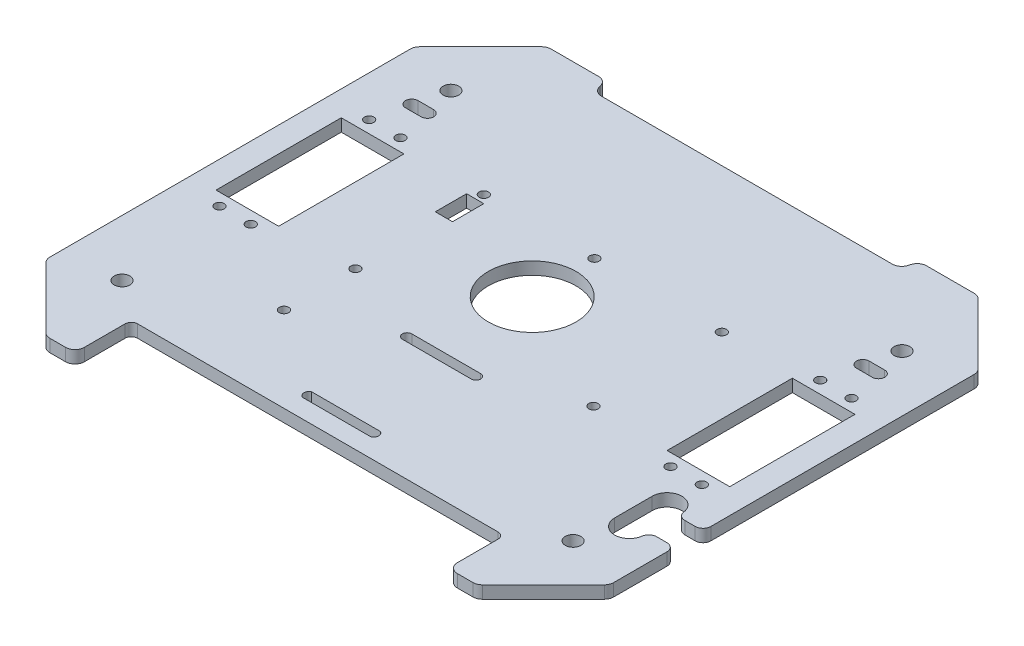
from build123d import *

# Parameters (mm, degrees)
BOSS_EXTRUDE1_DEPTH = 4
CUT_EXTRUDE1_REACH  = 123.301
SKETCH6_R           = 1.5
SKETCH6_R_2         = 2.5
SKETCH6_W           = 20
SKETCH6_H           = 40
SKETCH7_R           = 1.5
CUT_EXTRUDE2_DEPTH  = 122.300839153
SKETCH8_W           = 5.5
SKETCH8_H           = 10
CUT_EXTRUDE3_DEPTH  = 122.300839153
SKETCH9_R           = 1.5
SKETCH9_R_2         = 14
CUT_EXTRUDE4_DEPTH  = 122.300839153


with BuildPart() as part:
    # Sketch1 → Boss-Extrude1 (new body)
    with BuildSketch(Plane(origin=(0, 0, 0), x_dir=(1, 0, 0), z_dir=(0, 1, 0))):
        with BuildLine():
            Line((0, -78.772581113), (0, 81.227418887))
            Line((0, 81.227418887), (67.544155877, 81.227418887))
            ThreePointArc((67.544155877, 81.227418887), (68.692206174, 80.999057485), (69.665476221, 80.348739231))
            Line((69.665476221, 80.348739231), (89.121320344, 60.892895108))
            ThreePointArc((89.121320344, 60.892895108), (89.771638598, 59.919625062), (90, 58.771574765))
            Line((90, 58.771574765), (90, -56.31673699))
            ThreePointArc((90, -56.31673699), (89.771638598, -57.464787287), (89.121320344, -58.438057333))
            Line((89.121320344, -58.438057333), (69.665476221, -77.893901456))
            ThreePointArc((69.665476221, -77.893901456), (68.692206174, -78.54421971), (67.544155877, -78.772581113))
            Line((67.544155877, -78.772581113), (0, -78.772581113))
        make_face()
    boss_extrude1 = extrude(amount=BOSS_EXTRUDE1_DEPTH)

    # Sketch6 → Cut-Extrude1 (cut, up to next)
    with BuildSketch(Plane(origin=(0, 4, 0), x_dir=(1, 0, 0), z_dir=(0, 1, 0)), mode=Mode.PRIVATE) as cut_extrude1_sk1:
        with Locations(Location((67.009618943, 32.627418887, 0), (0, 0, 270))):
            Circle(SKETCH6_R)
    cut_extrude1_tool1 = extrude(cut_extrude1_sk1.sketch, amount=-CUT_EXTRUDE1_REACH, mode=Mode.PRIVATE) & part.part
    # Sketch6 → Cut-Extrude1 (cut, up to next)
    with BuildSketch(Plane(origin=(0, 4, 0), x_dir=(1, 0, 0), z_dir=(0, 1, 0)), mode=Mode.PRIVATE) as cut_extrude1_sk2:
        with Locations(Location((77.009618943, 32.627418887, 0), (0, 0, 270))):
            Circle(SKETCH6_R)
    cut_extrude1_tool2 = extrude(cut_extrude1_sk2.sketch, amount=-CUT_EXTRUDE1_REACH, mode=Mode.PRIVATE) & part.part
    # Sketch6 → Cut-Extrude1 (cut, up to next)
    with BuildSketch(Plane(origin=(0, 4, 0), x_dir=(1, 0, 0), z_dir=(0, 1, 0)), mode=Mode.PRIVATE) as cut_extrude1_sk3:
        with Locations(Location((77.009618943, -15.172581113, 0), (0, 0, 270))):
            Circle(SKETCH6_R)
    cut_extrude1_tool3 = extrude(cut_extrude1_sk3.sketch, amount=-CUT_EXTRUDE1_REACH, mode=Mode.PRIVATE) & part.part
    # Sketch6 → Cut-Extrude1 (cut, up to next)
    with BuildSketch(Plane(origin=(0, 4, 0), x_dir=(1, 0, 0), z_dir=(0, 1, 0)), mode=Mode.PRIVATE) as cut_extrude1_sk4:
        with Locations(Location((67.009618943, -15.172581113, 0), (0, 0, 270))):
            Circle(SKETCH6_R)
    cut_extrude1_tool4 = extrude(cut_extrude1_sk4.sketch, amount=-CUT_EXTRUDE1_REACH, mode=Mode.PRIVATE) & part.part
    # Sketch6 → Cut-Extrude1 (cut, up to next)
    with BuildSketch(Plane(origin=(0, 4, 0), x_dir=(1, 0, 0), z_dir=(0, 1, 0)), mode=Mode.PRIVATE) as cut_extrude1_sk5:
        with Locations(Location((72.009618943, 53.727418887, 0), (0, 0, 270))):
            Circle(SKETCH6_R_2)
    cut_extrude1_tool5 = extrude(cut_extrude1_sk5.sketch, amount=-CUT_EXTRUDE1_REACH, mode=Mode.PRIVATE) & part.part
    # Sketch6 → Cut-Extrude1 (cut, up to next)
    with BuildSketch(Plane(origin=(0, 4, 0), x_dir=(1, 0, 0), z_dir=(0, 1, 0)), mode=Mode.PRIVATE) as cut_extrude1_sk6:
        with Locations(Location((72.009618943, -51.272581113, 0), (0, 0, 270))):
            Circle(SKETCH6_R_2)
    cut_extrude1_tool6 = extrude(cut_extrude1_sk6.sketch, amount=-CUT_EXTRUDE1_REACH, mode=Mode.PRIVATE) & part.part
    # Sketch6 → Cut-Extrude1 (cut, up to next)
    with BuildSketch(Plane(origin=(0, 4, 0), x_dir=(1, 0, 0), z_dir=(0, 1, 0)), mode=Mode.PRIVATE) as cut_extrude1_sk7:
        with Locations((72.009618943, 8.727418887)):
            Rectangle(SKETCH6_W, SKETCH6_H)
    cut_extrude1_tool7 = extrude(cut_extrude1_sk7.sketch, amount=-CUT_EXTRUDE1_REACH, mode=Mode.PRIVATE) & part.part
    cut_extrude1_1 = cut_extrude1_tool1.solids().sort_by_distance((67.009619, 4, -32.627419))[0]
    add(cut_extrude1_1, mode=Mode.SUBTRACT)
    cut_extrude1_2 = cut_extrude1_tool2.solids().sort_by_distance((77.009619, 4, -32.627419))[0]
    add(cut_extrude1_2, mode=Mode.SUBTRACT)
    cut_extrude1_3 = cut_extrude1_tool3.solids().sort_by_distance((77.009619, 4, 15.172581))[0]
    add(cut_extrude1_3, mode=Mode.SUBTRACT)
    cut_extrude1_4 = cut_extrude1_tool4.solids().sort_by_distance((67.009619, 4, 15.172581))[0]
    add(cut_extrude1_4, mode=Mode.SUBTRACT)
    cut_extrude1_5 = cut_extrude1_tool5.solids().sort_by_distance((72.009619, 4, -53.727419))[0]
    add(cut_extrude1_5, mode=Mode.SUBTRACT)
    cut_extrude1_6 = cut_extrude1_tool6.solids().sort_by_distance((72.009619, 4, 51.272581))[0]
    add(cut_extrude1_6, mode=Mode.SUBTRACT)
    cut_extrude1_7 = cut_extrude1_tool7.solids().sort_by_distance((72.009619, 4, -8.727419))[0]
    add(cut_extrude1_7, mode=Mode.SUBTRACT)
    cut_extrude1 = cut_extrude1_1 + cut_extrude1_2 + cut_extrude1_3 + cut_extrude1_4 + cut_extrude1_5 + cut_extrude1_6 + cut_extrude1_7  # Cut-Extrude1 as one shape, for the pattern or mirror that repeats it

    # Sketch7 → Cut-Extrude2 (cut, through all)
    with BuildSketch(Plane(origin=(0, 4, 0), x_dir=(1, 0, 0), z_dir=(0, 1, 0))):
        with BuildLine():
            Line((11, -51.772581113), (0, -51.772581113))
            Line((0, -51.772581113), (0, -54.772581113))
            Line((0, -54.772581113), (11, -54.772581113))
            ThreePointArc((11, -54.772581113), (11.925367624, -53.272581113), (11, -51.772581113))
        make_face()
        with BuildLine():
            Line((0, -19.772581113), (0, -22.772581113))
            Line((0, -22.772581113), (11, -22.772581113))
            ThreePointArc((11, -22.772581113), (12.5, -21.272581113), (11, -19.772581113))
            Line((11, -19.772581113), (0, -19.772581113))
        make_face()
        with BuildLine():
            Line((57.544155877, -60.772581113), (0, -60.772581113))
            Line((0, -60.772581113), (0, -78.772581113))
            Line((0, -78.772581113), (62.544155877, -78.772581113))
            ThreePointArc((62.544155877, -78.772581113), (60.422835534, -77.893901456), (59.544155877, -75.772581113))
            Line((59.544155877, -75.772581113), (59.544155877, -62.772581113))
            ThreePointArc((59.544155877, -62.772581113), (58.95836944, -61.35836755), (57.544155877, -60.772581113))
        make_face()
        with BuildLine():
            Line((0, 81.227418887), (0, 76.227418887))
            Line((0, 76.227418887), (46.431936457, 76.227418887))
            ThreePointArc((46.431936457, 76.227418887), (48.258220744, 76.847358867), (49.329713936, 78.450961752))
            Line((49.329713936, 78.450961752), (49.477866868, 79.003876023))
            ThreePointArc((49.477866868, 79.003876023), (50.54936006, 80.607478908), (52.375644347, 81.227418887))
            Line((52.375644347, 81.227418887), (0, 81.227418887))
        make_face()
        with BuildLine():
            Line((74.509618943, 45.727418887), (69.509618943, 45.727418887))
            ThreePointArc((69.509618943, 45.727418887), (67.509618943, 43.727418887), (69.509618943, 41.727418887))
            Line((69.509618943, 41.727418887), (74.509618943, 41.727418887))
            ThreePointArc((74.509618943, 41.727418887), (76.509618943, 43.727418887), (74.509618943, 45.727418887))
        make_face()
        with Locations(Location((38, 30.227418887, 0), (0, 0, 270))):
            Circle(SKETCH7_R)
        with Locations(Location((38, -10.772581113, 0), (0, 0, 270))):
            Circle(SKETCH7_R)
    cut_extrude2 = extrude(amount=-CUT_EXTRUDE2_DEPTH, mode=Mode.SUBTRACT)

    # Mirror1: Boss-Extrude1, Cut-Extrude1, Cut-Extrude2 across plane
    add(boss_extrude1.mirror(Plane(origin=(0, 4, 78.772581113), x_dir=(0, 0, 1), z_dir=(1, 0, 0))))
    add(cut_extrude1.mirror(Plane(origin=(0, 4, 78.772581113), x_dir=(0, 0, 1), z_dir=(1, 0, 0))), mode=Mode.SUBTRACT)
    add(cut_extrude2.mirror(Plane(origin=(0, 4, 78.772581113), x_dir=(0, 0, 1), z_dir=(1, 0, 0))), mode=Mode.SUBTRACT)

    # Sketch8 → Cut-Extrude3 (cut, through all)
    with BuildSketch(Plane(origin=(0, 4, 0), x_dir=(1, 0, 0), z_dir=(0, 1, 0))):
        with Locations((-38.25, 22.727418887)):
            Rectangle(SKETCH8_W, SKETCH8_H)
        with BuildLine():
            Line((90, -25.272581113), (90, -39.272581113))
            ThreePointArc((90, -39.272581113), (89.267766953, -37.50481416), (87.5, -36.772581113))
            Line((87.5, -36.772581113), (84.174158586, -36.772581113))
            ThreePointArc((84.174158586, -36.772581113), (82.533118782, -37.386583137), (81.698160388, -38.926990423))
            ThreePointArc((81.698160388, -38.926990423), (76.681626099, -42.995196185), (72.27562777, -38.272581113))
            Line((72.27562777, -38.272581113), (72.27562777, -26.272581113))
            ThreePointArc((72.27562777, -26.272581113), (76.681626099, -21.549966041), (81.698160388, -25.618171802))
            ThreePointArc((81.698160388, -25.618171802), (82.533118782, -27.158579088), (84.174158586, -27.772581113))
            Line((84.174158586, -27.772581113), (87.5, -27.772581113))
            ThreePointArc((87.5, -27.772581113), (89.267766953, -27.040348066), (90, -25.272581113))
        make_face()
    extrude(amount=-CUT_EXTRUDE3_DEPTH, mode=Mode.SUBTRACT)

    # Sketch9 → Cut-Extrude4 (cut, through all)
    with BuildSketch(Plane(origin=(0, 4, 0), x_dir=(1, 0, 0), z_dir=(0, 1, 0))):
        with Locations(Location((-2.69, 30.227418887, 0), (0, 0, 270))):
            Circle(SKETCH9_R)
        with Locations(Location((-38, -33.572581113, 0), (0, 0, 270))):
            Circle(SKETCH9_R)
        with Locations(Location((-2.06, 9.727418887, 0), (0, 0, 270))):
            Circle(SKETCH9_R_2)
    extrude(amount=-CUT_EXTRUDE4_DEPTH, mode=Mode.SUBTRACT)


solid = part.part
